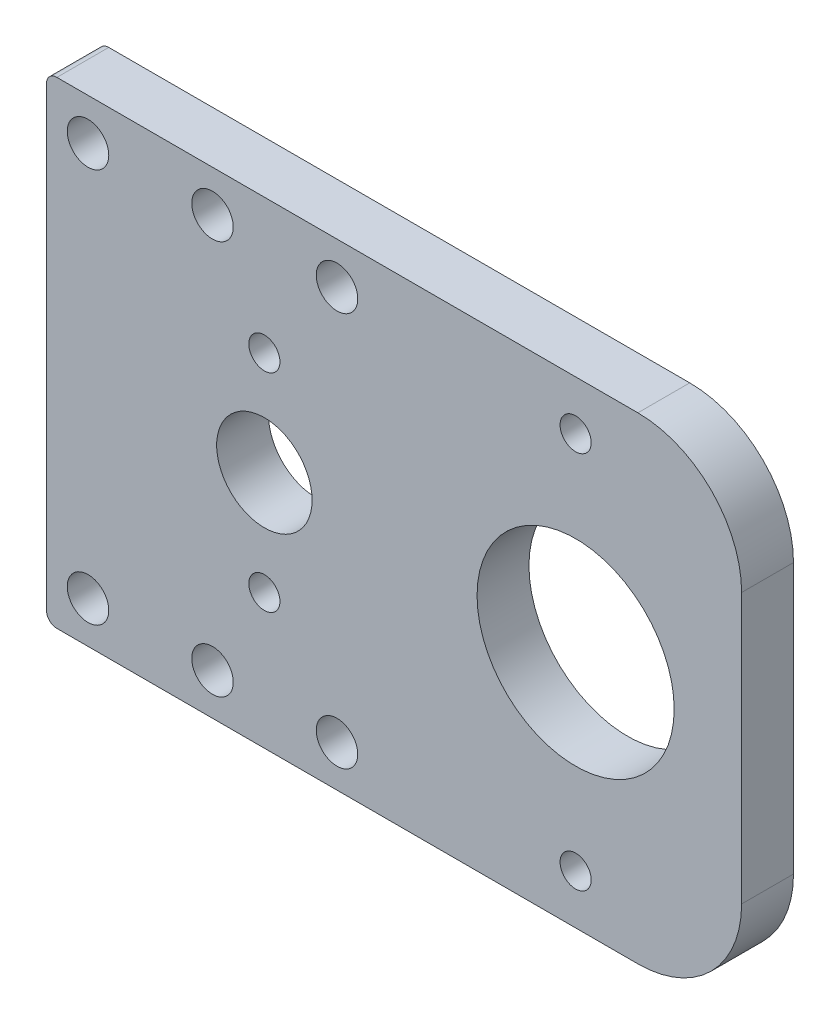
from build123d import *

# Parameters (mm, degrees)
SKETCH1_W           = 65
SKETCH1_H           = 46
SKETCH1_R           = 1.5
BOSS_EXTRUDE1_DEPTH = 5
SKETCH2_R           = 2
CUT_EXTRUDE1_DEPTH  = 10
SKETCH3_W           = 4
SKETCH3_H           = 46
CUT_EXTRUDE2_DEPTH  = 6
SKETCH4_W           = 6
SKETCH4_H           = 46
BOSS_EXTRUDE2_DEPTH = 5
FILLET1_R           = 10
FILLET2_R           = 1


with BuildPart() as part:
    # Sketch1 → Boss-Extrude1 (new body)
    with BuildSketch(Plane.XY):
        with Locations((7.5, 0)):
            Rectangle(SKETCH1_W, SKETCH1_H)
        with BuildLine():
            ThreePointArc((4.6, 0), (3.252691193, -3.252691193), (0, -4.6))
            ThreePointArc((0, -4.6), (-3.252691193, 3.252691193), (4.6, 0))
        make_face(mode=Mode.SUBTRACT)
        with Locations((30, -18.25)):
            Circle(SKETCH1_R, mode=Mode.SUBTRACT)
        with BuildLine():
            ThreePointArc((1.5, -10), (-1.060660172, -11.060660172), (0, -8.5))
            ThreePointArc((0, -8.5), (1.060660172, -8.939339828), (1.5, -10))
        make_face(mode=Mode.SUBTRACT)
        with BuildLine():
            ThreePointArc((39.5, 0), (23.282485579, -6.717514421), (30, 9.5))
            ThreePointArc((30, 9.5), (36.717514421, 6.717514421), (39.5, 0))
        make_face(mode=Mode.SUBTRACT)
        with Locations((0, 10)):
            Circle(SKETCH1_R, mode=Mode.SUBTRACT)
        with BuildLine():
            ThreePointArc((31.5, 18.25), (31.060660172, 17.189339828), (30, 16.75))
            ThreePointArc((30, 16.75), (28.939339828, 19.310660172), (31.5, 18.25))
        make_face(mode=Mode.SUBTRACT)
    extrude(amount=BOSS_EXTRUDE1_DEPTH)

    # Sketch2 → Cut-Extrude1 (cut)
    with BuildSketch(Plane.XY.offset(5)):
        with Locations((7, 19)):
            Circle(SKETCH2_R)
        with Locations((-5, -19)):
            Circle(SKETCH2_R)
        with Locations((-17, 19)):
            Circle(SKETCH2_R)
        with Locations((-5, 19)):
            Circle(SKETCH2_R)
        with Locations((7, -19)):
            Circle(SKETCH2_R)
        with Locations((-17, -19)):
            Circle(SKETCH2_R)
    extrude(amount=-CUT_EXTRUDE1_DEPTH, mode=Mode.SUBTRACT)

    # Sketch3 → Cut-Extrude2 (cut, through all)
    with BuildSketch(Plane.XY.offset(5)):
        with Locations((-23, 0)):
            Rectangle(SKETCH3_W, SKETCH3_H)
    extrude(amount=-CUT_EXTRUDE2_DEPTH, mode=Mode.SUBTRACT)

    # Sketch4 → Boss-Extrude2 (add)
    with BuildSketch(Plane.XY.offset(5)):
        with Locations((43, 0)):
            Rectangle(SKETCH4_W, SKETCH4_H)
    extrude(amount=-BOSS_EXTRUDE2_DEPTH)

    # Fillet1
    fillet1_edges = [part.edges().sort_by_distance(p)[0] for p in [
        (46, -23, 2.5),
        (46, 23, 2.5),
    ]]
    fillet(fillet1_edges, radius=FILLET1_R)

    # Fillet2
    fillet2_edges = [part.edges().sort_by_distance(p)[0] for p in [
        (-21, 23, 2.5),
        (-21, -23, 2.5),
    ]]
    fillet(fillet2_edges, radius=FILLET2_R)


solid = part.part
